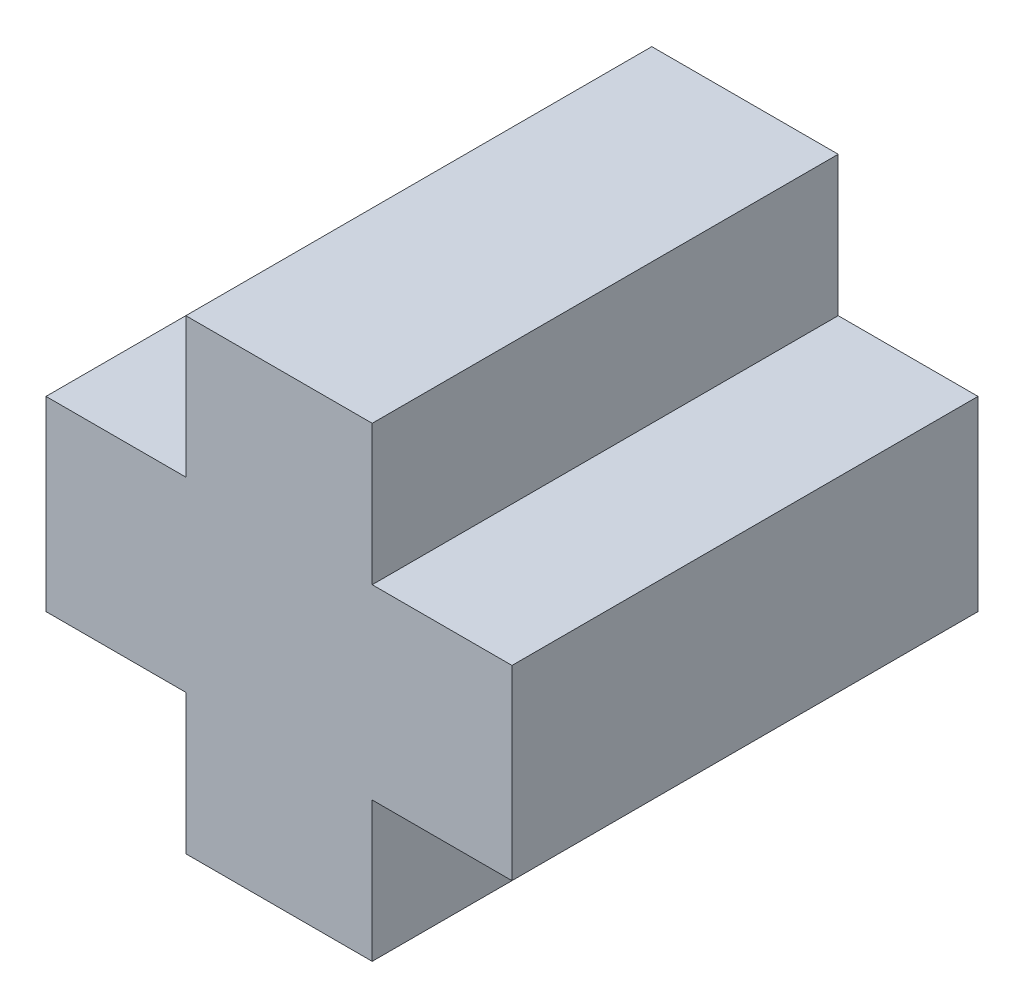
from build123d import *

# Parameters (mm, degrees)
BOSS_EXTRUDE1_DEPTH = 10


with BuildPart() as part:
    # Sketch1 → Boss-Extrude1 (new body)
    with BuildSketch(Plane.XY):
        Polygon((-5.949275362, 6.547101449), (-5.949275362, 3.547101449), (-8.949275362, 3.547101449), (-8.949275362, -0.452898551), (-5.949275362, -0.452898551), (-5.949275362, -3.452898551), (-1.949275362, -3.452898551), (-1.949275362, -0.452898551), (1.050724638, -0.452898551), (1.050724638, 3.547101449), (-1.949275362, 3.547101449), (-1.949275362, 6.547101449), align=None)
    extrude(amount=BOSS_EXTRUDE1_DEPTH)


solid = part.part
